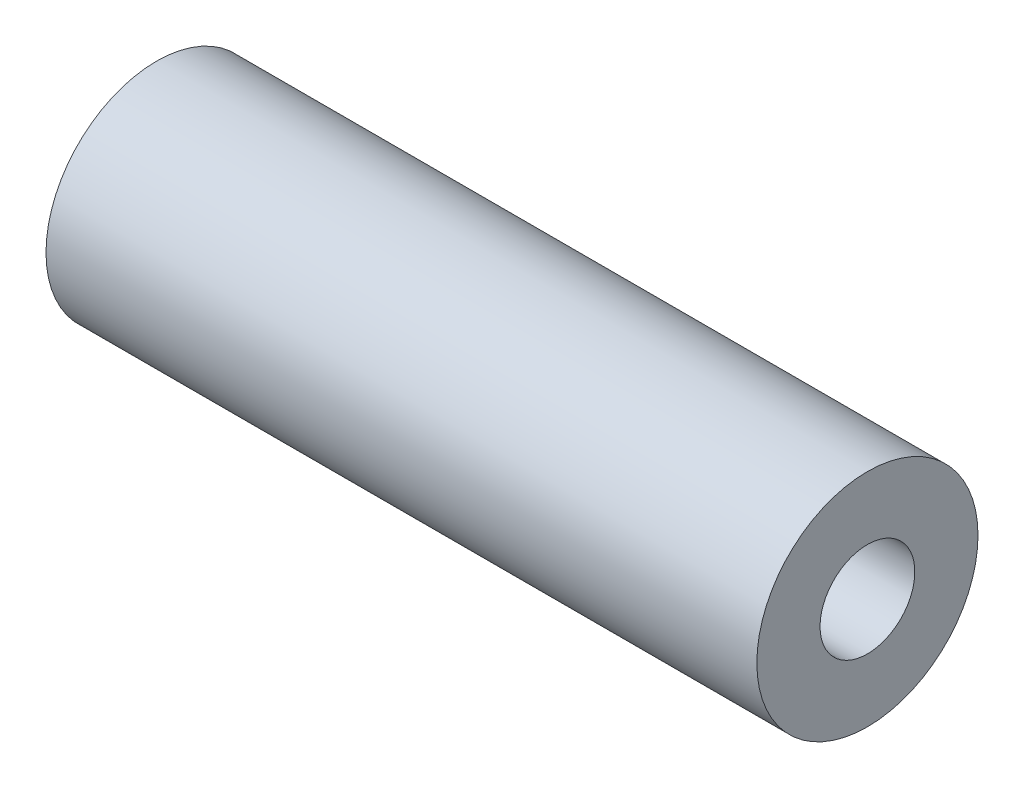
from build123d import *

# Parameters (mm, degrees)
SKETCH1_W = 45
SKETCH1_H = 4


with BuildPart() as part:
    # Sketch1 → Revolve1 (revolve)
    with BuildSketch(Plane.XY):
        with Locations((0, 5)):
            Rectangle(SKETCH1_W, SKETCH1_H)
    revolve(axis=Axis((-37.003163219, 0, 0), (1, 0, 0)))


solid = part.part
